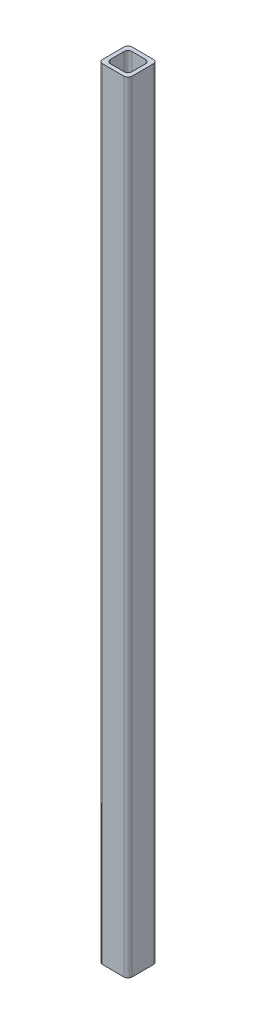
from build123d import *

# Parameters (mm, degrees)
BOSS_EXTRUDE1_DEPTH = 800


with BuildPart() as part:
    # Sketch1 → Boss-Extrude1 (new body)
    with BuildSketch(Plane(origin=(0, 0, 0), x_dir=(1, 0, 0), z_dir=(0, 1, 0))):
        with BuildLine():
            Line((11, 15), (-11, 15))
            ThreePointArc((-11, 15), (-13.828427125, 13.828427125), (-15, 11))
            Line((-15, 11), (-15, -11))
            ThreePointArc((-15, -11), (-13.828427125, -13.828427125), (-11, -15))
            Line((-11, -15), (11, -15))
            ThreePointArc((11, -15), (13.828427125, -13.828427125), (15, -11))
            Line((15, -11), (15, 11))
            ThreePointArc((15, 11), (13.828427125, 13.828427125), (11, 15))
        make_face()
        with BuildLine():
            Line((7, 11), (-7, 11))
            ThreePointArc((-7, 11), (-9.828427125, 9.828427125), (-11, 7))
            Line((-11, 7), (-11, -7))
            ThreePointArc((-11, -7), (-9.828427125, -9.828427125), (-7, -11))
            Line((-7, -11), (7, -11))
            ThreePointArc((7, -11), (9.828427125, -9.828427125), (11, -7))
            Line((11, -7), (11, 7))
            ThreePointArc((11, 7), (9.828427125, 9.828427125), (7, 11))
        make_face(mode=Mode.SUBTRACT)
    extrude(amount=BOSS_EXTRUDE1_DEPTH)


solid = part.part
